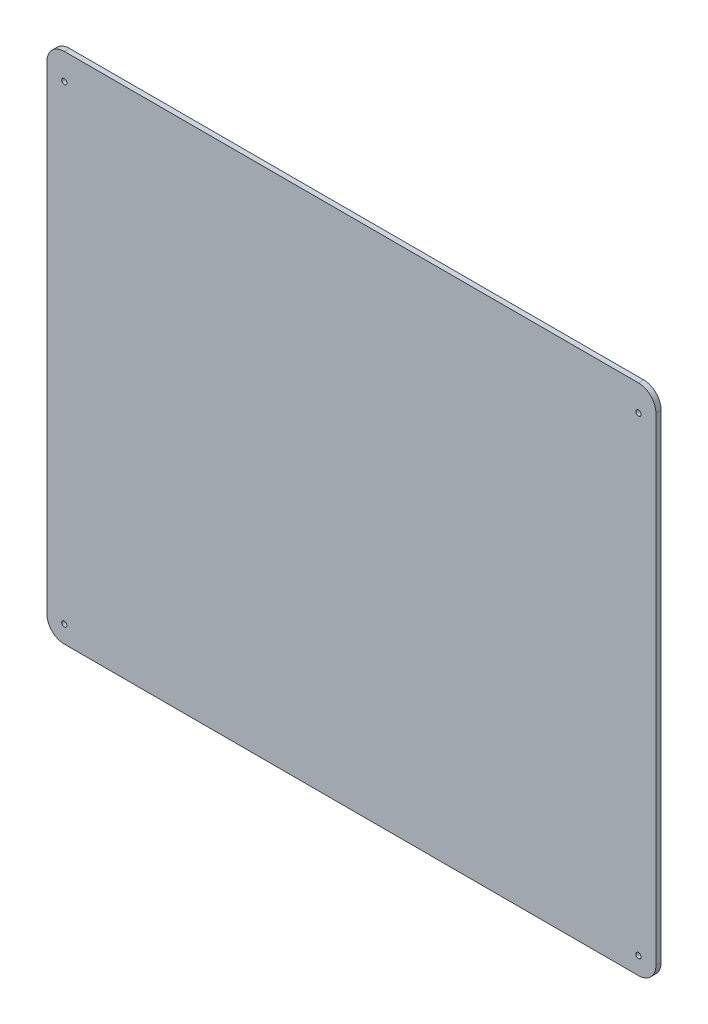
from build123d import *

# Parameters (mm, degrees)
ESQUISSE1_R        = 1.5
BOSS_EXTRU_1_DEPTH = 3


with BuildPart() as part:
    # Esquisse1 → Boss.-Extru.1 (new body)
    with BuildSketch(Plane.XY):
        with BuildLine():
            Line((10, 0), (340, 0))
            ThreePointArc((340, 0), (347.071067812, 2.928932188), (350, 10))
            Line((350, 10), (350, 285))
            ThreePointArc((350, 285), (347.071067812, 292.071067812), (340, 295))
            Line((340, 295), (10, 295))
            ThreePointArc((10, 295), (2.928932188, 292.071067812), (0, 285))
            Line((0, 285), (0, 10))
            ThreePointArc((0, 10), (2.928932188, 2.928932188), (10, 0))
        make_face()
        with Locations((340, 280)):
            Circle(ESQUISSE1_R, mode=Mode.SUBTRACT)
        with Locations((10, 280)):
            Circle(ESQUISSE1_R, mode=Mode.SUBTRACT)
        with Locations((10, 10)):
            Circle(ESQUISSE1_R, mode=Mode.SUBTRACT)
        with Locations((340, 10)):
            Circle(ESQUISSE1_R, mode=Mode.SUBTRACT)
    extrude(amount=BOSS_EXTRU_1_DEPTH)


solid = part.part
